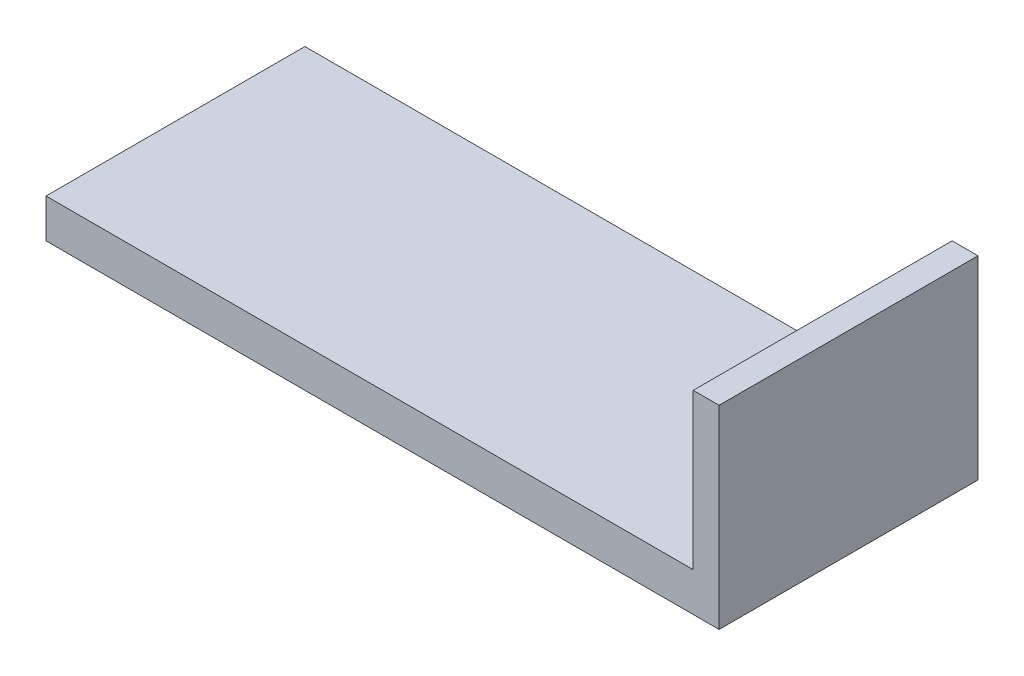
from build123d import *

# Parameters (mm, degrees)
BOSS_EXTRUDE1_DEPTH = 2000


with BuildPart() as part:
    # Sketch1 → Boss-Extrude1 (new body)
    with BuildSketch(Plane.XY):
        Polygon((0, 0), (5000, 0), (5000, 1200), (5200, 1200), (5200, -300), (0, -300), align=None)
    extrude(amount=BOSS_EXTRUDE1_DEPTH)


solid = part.part
